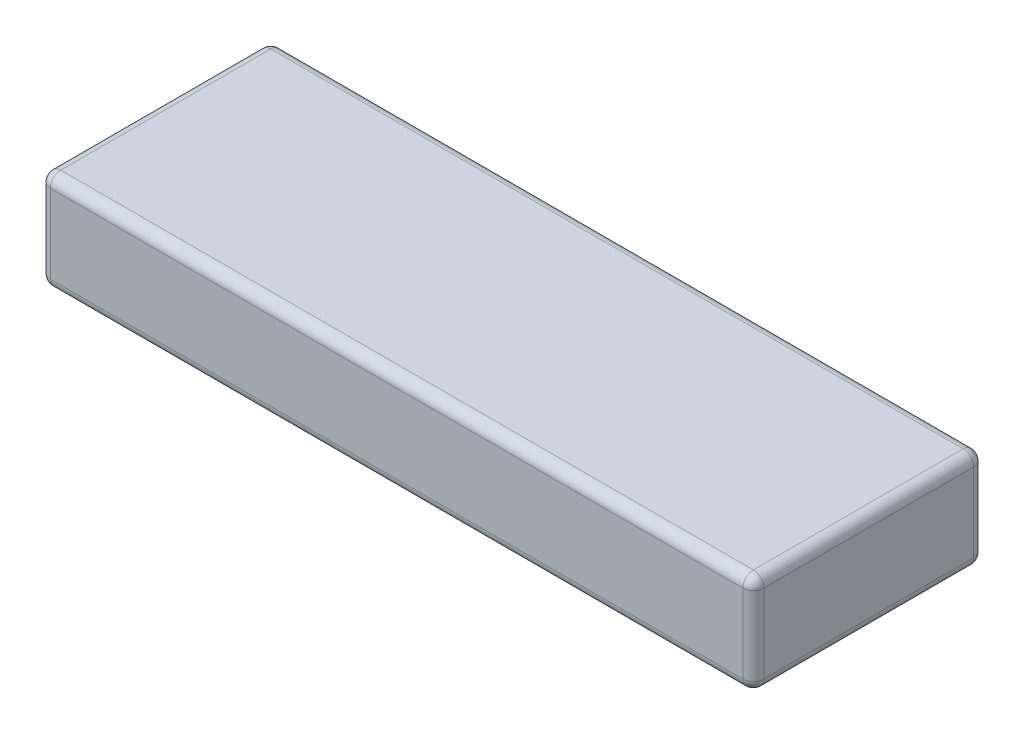
from build123d import *

# Parameters (mm, degrees)
SKETCH1_W           = 136
SKETCH1_H           = 44
BOSS_EXTRUDE1_DEPTH = 19
FILLET1_R           = 2


with BuildPart() as part:
    # Sketch1 → Boss-Extrude1 (new body)
    with BuildSketch(Plane(origin=(0, 0, 0), x_dir=(1, 0, 0), z_dir=(0, 1, 0))):
        Rectangle(SKETCH1_W, SKETCH1_H)
    extrude(amount=BOSS_EXTRUDE1_DEPTH)

    # Fillet1
    fillet1_edges = [part.edges().sort_by_distance(p)[0] for p in [
        (-68, 19, 0),
        (0, 19, 22),
        (68, 19, 0),
        (0, 0, 22),
        (-68, 0, 0),
        (0, 0, -22),
        (68, 0, 0),
        (68, 9.5, 22),
        (-68, 9.5, 22),
        (-68, 9.5, -22),
        (68, 9.5, -22),
        (0, 19, -22),
    ]]
    fillet(fillet1_edges, radius=FILLET1_R)


solid = part.part
